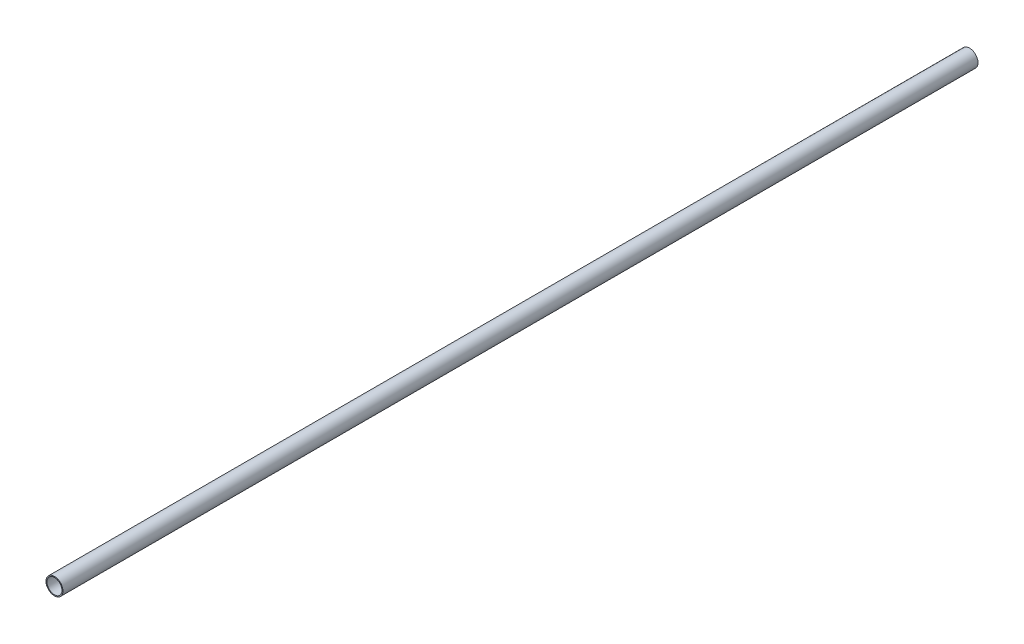
from build123d import *

# Parameters (mm, degrees)
PIPESKETCH_R    = 50.8
PIPESKETCH_R_2  = 45.0596
EXTRUSION_DEPTH = 5486.4


with BuildPart() as part:
    # PipeSketch → Extrusion (new body)
    with BuildSketch(Plane.XY):
        Circle(PIPESKETCH_R)
        Circle(PIPESKETCH_R_2, mode=Mode.SUBTRACT)
    extrude(amount=EXTRUSION_DEPTH)


solid = part.part
